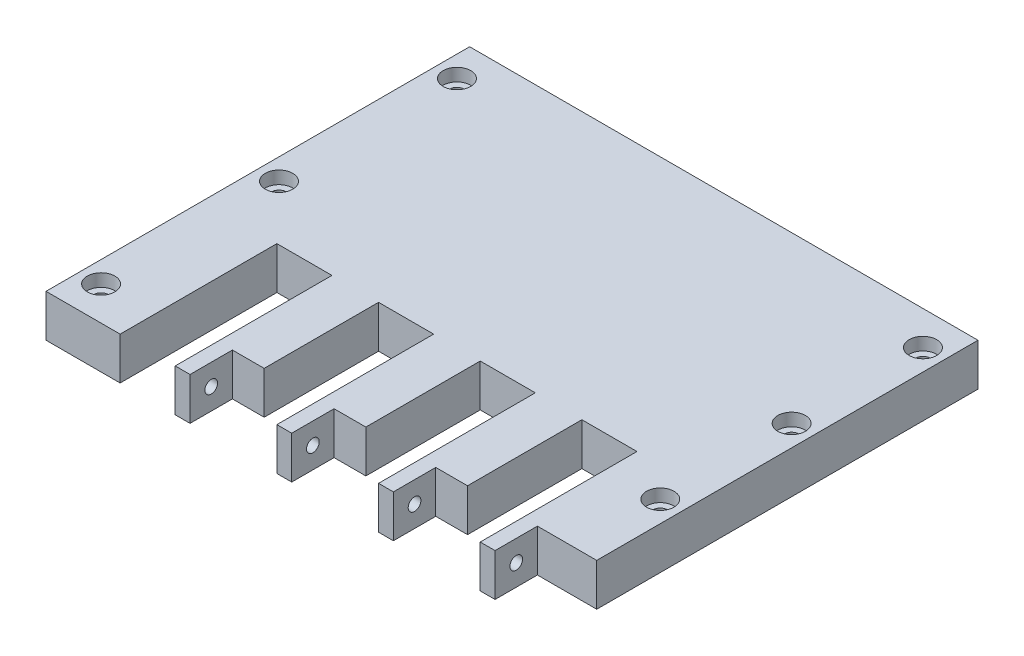
from build123d import *

# Parameters (mm, degrees)
SKETCH1_W                     = 120
SKETCH1_H                     = 100
BOSS_EXTRUDE1_DEPTH           = 10
SKETCH2_W                     = 13
SKETCH2_H                     = 20
CUT_EXTRUDE1_DEPTH            = 37
SKETCH3_W                     = 14
SKETCH3_H                     = 10
SKETCH3_W_2                   = 7.5
CUT_EXTRUDE4_DEPTH            = 10
SKETCH10_R                    = 1.5
CUT_EXTRUDE5_DEPTH            = 75.5
CBORE_FOR_M3_SHCS_D           = 3.4
CBORE_FOR_M3_SHCS_DEPTH       = 23
CBORE_FOR_M3_SHCS_CBORE_D     = 6.5
CBORE_FOR_M3_SHCS_CBORE_DEPTH = 3
CBORE_FOR_M3_SHCS_TIP         = 1.021463052


with BuildPart() as part:
    # Sketch1 → Boss-Extrude1 (new body)
    with BuildSketch(Plane(origin=(0, 0, 0), x_dir=(1, 0, 0), z_dir=(0, 1, 0))):
        Rectangle(SKETCH1_W, SKETCH1_H)
    extrude(amount=BOSS_EXTRUDE1_DEPTH)

    # Sketch2 → Cut-Extrude1 (cut)
    with BuildSketch(Plane.XY.offset(50)):
        with Locations((-36, 0)):
            Rectangle(SKETCH2_W, SKETCH2_H)
        with Locations((-12, 0)):
            Rectangle(SKETCH2_W, SKETCH2_H)
        with Locations((12, 0)):
            Rectangle(SKETCH2_W, SKETCH2_H)
        with Locations((36, 0)):
            Rectangle(SKETCH2_W, SKETCH2_H)
    extrude(amount=-CUT_EXTRUDE1_DEPTH, mode=Mode.SUBTRACT)

    # Sketch3 → Cut-Extrude4 (cut)
    with BuildSketch(Plane.XY.offset(50)):
        with Locations((53, 5)):
            Rectangle(SKETCH3_W, SKETCH3_H)
        with Locations((25.75, 5)):
            Rectangle(SKETCH3_W_2, SKETCH3_H)
        with Locations((1.75, 5)):
            Rectangle(SKETCH3_W_2, SKETCH3_H)
        with Locations((-22.25, 5)):
            Rectangle(SKETCH3_W_2, SKETCH3_H)
    extrude(amount=-CUT_EXTRUDE4_DEPTH, mode=Mode.SUBTRACT)

    # Sketch10 → Cut-Extrude5 (cut)
    with BuildSketch(Plane(origin=(46, 0, 0), x_dir=(0, 0, -1), z_dir=(1, 0, 0))):
        with Locations((-45, 5)):
            Circle(SKETCH10_R)
    extrude(amount=-CUT_EXTRUDE5_DEPTH, mode=Mode.SUBTRACT)

    # CBORE for M3 SHCS
    with Locations(Plane(origin=(-676.293536786, 10, -1323.282701689), x_dir=(1, 0, 0), z_dir=(0, 1, 0))):
        with Locations((731.293536786, -1281.282701689), (731.293536786, -1343.282701689), (621.293536786, -1281.282701689), (621.293536786, -1365.282701689), (621.293536786, -1323.282701689), (731.293536786, -1312.282701689)):
            CounterBoreHole(CBORE_FOR_M3_SHCS_D / 2, CBORE_FOR_M3_SHCS_CBORE_D / 2, CBORE_FOR_M3_SHCS_CBORE_DEPTH, depth=CBORE_FOR_M3_SHCS_DEPTH)
            with Locations((0, 0, -(CBORE_FOR_M3_SHCS_DEPTH + CBORE_FOR_M3_SHCS_TIP / 2))):  # 118° drill point
                Cone(0, CBORE_FOR_M3_SHCS_D / 2, CBORE_FOR_M3_SHCS_TIP, mode=Mode.SUBTRACT)


solid = part.part
